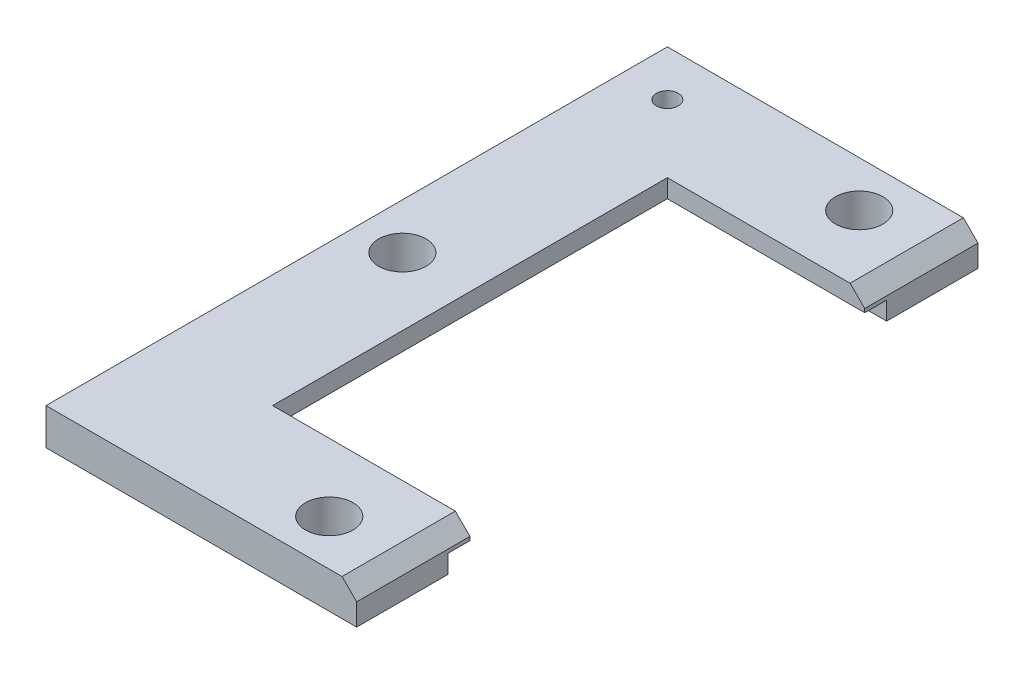
from build123d import *

# Parameters (mm, degrees)
BOSS_EXTRUDE1_DEPTH = 10
CUT_EXTRUDE1_DEPTH  = 5
CHAMFER1_SIZE       = 4
SKETCH3_R           = 6.5
CUT_EXTRUDE2_DEPTH  = 11
SKETCH7_R           = 3
CUT_EXTRUDE3_DEPTH  = 11


with BuildPart() as part:
    # Sketch1 → Boss-Extrude1 (new body)
    with BuildSketch(Plane(origin=(0, 0, 0), x_dir=(1, 0, 0), z_dir=(0, 1, 0))):
        Polygon((-133.17660268, -85), (-133.17660268, -54), (-187.17660268, -54), (-187.17660268, 54), (-133.17660268, 54), (-133.17660268, 85), (-218.17660268, 85), (-218.17660268, -85), align=None)
    extrude(amount=BOSS_EXTRUDE1_DEPTH)

    # Sketch2 → Cut-Extrude1 (cut)
    with BuildSketch(Plane.XZ):
        Polygon((-133.17660268, 60), (-193.17660268, 60), (-193.17660268, -60), (-133.17660268, -60), (-133.17660268, -54), (-187.17660268, -54), (-187.17660268, 54), (-133.17660268, 54), align=None)
    extrude(amount=-CUT_EXTRUDE1_DEPTH, mode=Mode.SUBTRACT)

    # Chamfer1
    chamfer1_edges = [part.edges().sort_by_distance(p)[0] for p in [
        (-133.17660268, 10, 69.5),
        (-133.17660268, 10, -69.5),
    ]]
    chamfer(chamfer1_edges, length=CHAMFER1_SIZE)

    # Sketch3 → Cut-Extrude2 (cut, through all)
    with BuildSketch(Plane.XZ):
        with Locations((-153.17660268, -72.5)):
            Circle(SKETCH3_R)
        with Locations((-153.17660268, 72.5)):
            Circle(SKETCH3_R)
        with Locations((-205.676562711, 0)):
            Circle(SKETCH3_R)
    extrude(amount=-CUT_EXTRUDE2_DEPTH, mode=Mode.SUBTRACT)

    # Sketch7 → Cut-Extrude3 (cut, through all)
    with BuildSketch(Plane.XZ):
        with Locations((-205.67660268, -72.5)):
            Circle(SKETCH7_R)
    extrude(amount=-CUT_EXTRUDE3_DEPTH, mode=Mode.SUBTRACT)


solid = part.part
